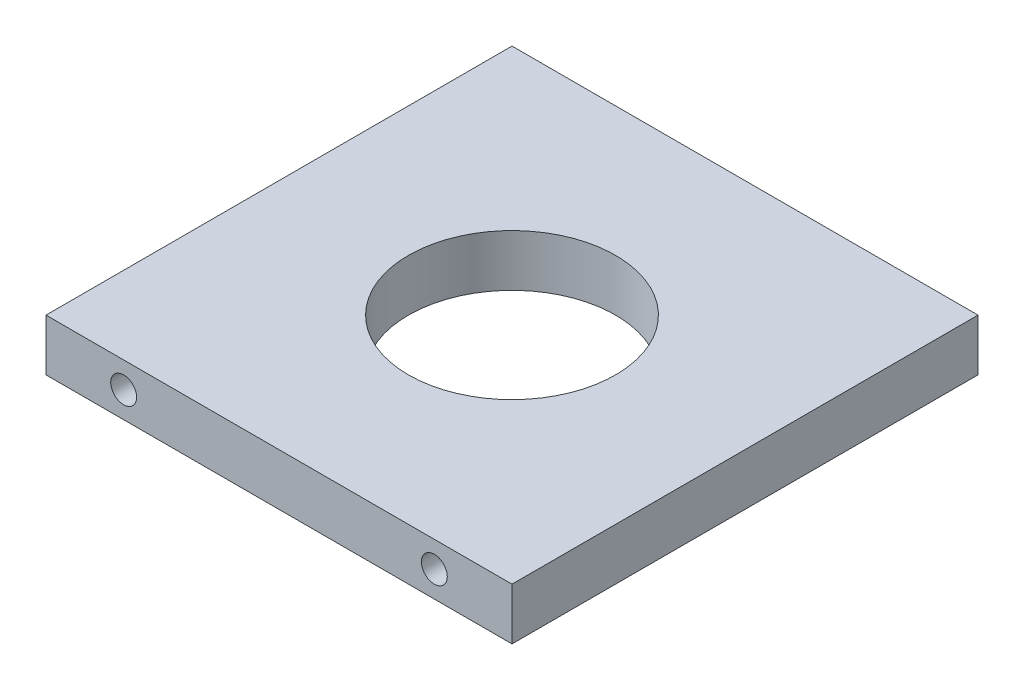
from build123d import *

# Parameters (mm, degrees)
SKETCH1_W           = 57.15
SKETCH1_H           = 57.15
SKETCH1_R           = 12.7
BOSS_EXTRUDE1_DEPTH = 6.35
SKETCH2_R           = 1.5875
CUT_EXTRUDE1_DEPTH  = 12.7


with BuildPart() as part:
    # Sketch1 → Boss-Extrude1 (new body)
    with BuildSketch(Plane(origin=(0, 0, 0), x_dir=(1, 0, 0), z_dir=(0, 1, 0))):
        Rectangle(SKETCH1_W, SKETCH1_H)
        Circle(SKETCH1_R, mode=Mode.SUBTRACT)
    extrude(amount=BOSS_EXTRUDE1_DEPTH)

    # Sketch2 → Cut-Extrude1 (cut)
    with BuildSketch(Plane.XY.offset(28.575)):
        with Locations((-19.05, 3.175)):
            Circle(SKETCH2_R)
        with Locations((19.05, 3.175)):
            Circle(SKETCH2_R)
    extrude(amount=-CUT_EXTRUDE1_DEPTH, mode=Mode.SUBTRACT)


solid = part.part
